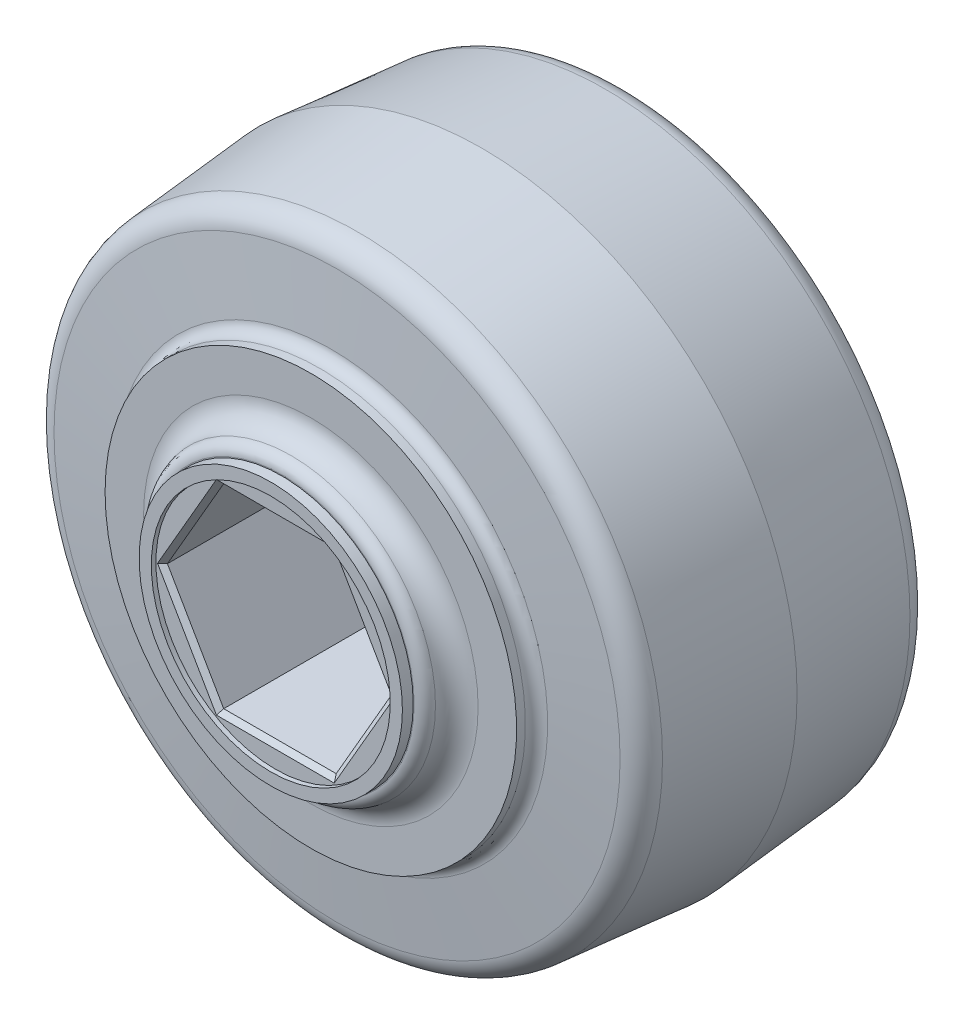
from build123d import *

# Parameters (mm, degrees)
SKETCH2_R           = 8.603491183
BOSS_EXTRUDE1_DEPTH = 0.70005
BOSS_EXTRUDE1_TAPER = 0.5
SKETCH3_R           = 8.603491183
BOSS_EXTRUDE2_DEPTH = 0.70005
BOSS_EXTRUDE2_TAPER = 0.5
CUT_EXTRUDE1_DEPTH  = 28.5875
CHAMFER1_SIZE       = 0.3
FILLET1_R           = 0.762
FILLET2_R           = 1.524


with BuildPart() as part:
    # Sketch1 → Revolve1 (revolve)
    with BuildSketch(Plane.XZ):
        with BuildLine():
            Line((9.449730898, 13.0937), (0, 13.0937))
            Line((0, 13.0937), (0, -13.0937))
            Line((0, -13.0937), (9.449730898, -13.0937))
            ThreePointArc((9.449730898, -13.0937), (9.71316279, -11.771943644), (10.922, -11.176))
            Line((10.922, -11.176), (13.4366, -11.176))
            Line((13.4366, -11.176), (13.4366, -9.906))
            Line((13.4366, -9.906), (19.755705414, -9.353149913))
            Line((19.755705414, -9.353149913), (20.574, 0))
            Line((20.574, 0), (19.755705414, 9.353149913))
            Line((19.755705414, 9.353149913), (13.4366, 9.906))
            Line((13.4366, 9.906), (13.4366, 11.176))
            Line((13.4366, 11.176), (10.922, 11.176))
            ThreePointArc((10.922, 11.176), (9.71316279, 11.771943644), (9.449730898, 13.0937))
        make_face()
    revolve(axis=Axis((0, 0, 13.0937), (0, 0, -1)))

    # Sketch2 → Boss-Extrude1 (add)
    with BuildSketch(Plane.XY.offset(13.0937)):
        Circle(SKETCH2_R)
    extrude(amount=BOSS_EXTRUDE1_DEPTH, taper=BOSS_EXTRUDE1_TAPER)

    # Sketch3 → Boss-Extrude2 (add)
    with BuildSketch(Plane(origin=(0, 0, -13.0937), x_dir=(-1, 0, 0), z_dir=(0, 0, -1))):
        Circle(SKETCH3_R)
    extrude(amount=BOSS_EXTRUDE2_DEPTH, taper=BOSS_EXTRUDE2_TAPER)

    # Sketch4 → Cut-Extrude1 (cut, through all)
    with BuildSketch(Plane(origin=(0, 0, -13.79375), x_dir=(-1, 0, 0), z_dir=(0, 0, -1))):
        Polygon((7.347013116, 0), (3.673506558, 6.3627), (-3.673506558, 6.3627), (-7.347013116, 0), (-3.673506558, -6.3627), (3.673506558, -6.3627), align=None)
    extrude(amount=-CUT_EXTRUDE1_DEPTH, mode=Mode.SUBTRACT)

    # Sketch5 → Cut-Revolve1 (revolve, cut)
    with BuildSketch(Plane(origin=(0, 0, 0), x_dir=(0, 0, -1), z_dir=(1, 0, 0))):
        Polygon((13.79375, 0), (13.79375, 7.80261806), (13.49375, 7.8), (13.49375, 0), align=None)
    revolve(axis=Axis((0, 0, -13.49375), (0, 0, -1)), mode=Mode.SUBTRACT)

    # Sketch6 → Cut-Revolve2 (revolve, cut)
    with BuildSketch(Plane(origin=(0, 0, 0), x_dir=(0, 0, -1), z_dir=(1, 0, 0))):
        Polygon((-13.79375, 0), (-13.79375, -7.80261806), (-13.49375, -7.8), (-13.49375, 0), align=None)
    revolve(axis=Axis((0, 0, 13.49375), (0, 0, 1)), mode=Mode.SUBTRACT)

    # Chamfer1
    chamfer1_edges = [part.edges().sort_by_distance(p)[0] for p in [
        (-5.510259837, 3.18135, -13.49375),
        (0, -6.3627, -13.49375),
        (-5.510259837, -3.18135, -13.49375),
        (0, 6.3627, -13.49375),
        (5.510259837, 3.18135, -13.49375),
        (5.510259837, -3.18135, -13.49375),
        (-5.510259837, 3.18135, 13.49375),
        (-5.510259837, -3.18135, 13.49375),
        (0, -6.3627, 13.49375),
        (5.510259837, -3.18135, 13.49375),
        (5.510259837, 3.18135, 13.49375),
        (0, 6.3627, 13.49375),
    ]]
    chamfer(chamfer1_edges, length=CHAMFER1_SIZE)

    # Fillet1
    fillet1_edges = [part.edges().sort_by_distance(p)[0] for p in [
        (-9.449730898, 0, -13.0937),
        (-13.4366, 0, -9.906),
        (-13.4366, 0, 9.906),
        (-9.449730898, 0, 13.0937),
    ]]
    fillet(fillet1_edges, radius=FILLET1_R)

    # Fillet2
    fillet2_edges = [part.edges().sort_by_distance(p)[0] for p in [
        (-19.755705414, 0, -9.353149913),
        (-19.755705414, 0, 9.353149913),
    ]]
    fillet(fillet2_edges, radius=FILLET2_R)


solid = part.part
